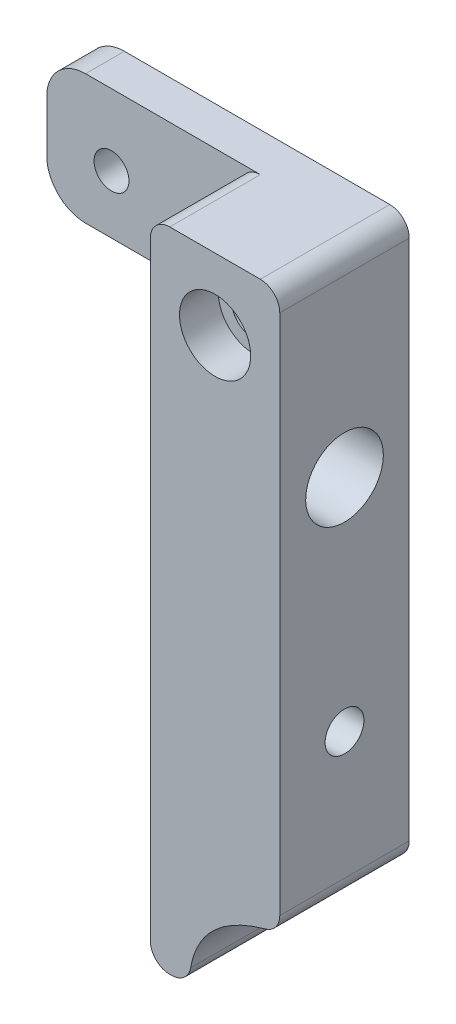
from build123d import *

# Parameters (mm, degrees)
SKETCH1_W           = 10
SKETCH1_H           = 50
BOSS_EXTRUDE1_DEPTH = 10
SKETCH2_R           = 1.75
CUT_EXTRUDE1_DEPTH  = 10
CUT_EXTRUDE2_DEPTH  = 10
FILLET1_R           = 1.5
SKETCH4_R           = 2.75
CUT_EXTRUDE3_DEPTH  = 3
SKETCH5_R           = 3
CUT_EXTRUDE4_DEPTH  = 13
SKETCH6_W           = 3
SKETCH6_H           = 10
BOSS_EXTRUDE2_DEPTH = 15
FILLET2_R           = 3
FILLET3_R           = 1.5
SKETCH7_R           = 1.35
CUT_EXTRUDE5_DEPTH  = 15
SKETCH8_R           = 1.5
CUT_EXTRUDE6_DEPTH  = 15


with BuildPart() as part:
    # Sketch1 → Boss-Extrude1 (new body)
    with BuildSketch(Plane.XY):
        Rectangle(SKETCH1_W, SKETCH1_H)
    extrude(amount=BOSS_EXTRUDE1_DEPTH)

    # Sketch2 → Cut-Extrude1 (cut)
    with BuildSketch(Plane.XY.offset(10)):
        with Locations((0, 19.5)):
            Circle(SKETCH2_R)
    extrude(amount=-CUT_EXTRUDE1_DEPTH, mode=Mode.SUBTRACT)

    # Sketch3 → Cut-Extrude2 (cut)
    with BuildSketch(Plane.XY.offset(10)):
        with BuildLine():
            Line((5, -18), (5, -25))
            Line((5, -25), (-2, -25))
            add(Edge.make_bspline(
                [(-2, -25), (-1.904224842, -19.430935455), (5, -18)],
                knots=[0, 0, 0, 1, 1, 1], degree=2))
        make_face()
    extrude(amount=-CUT_EXTRUDE2_DEPTH, mode=Mode.SUBTRACT)

    # Fillet1
    fillet1_edges = [part.edges().sort_by_distance(p)[0] for p in [
        (5, -18, 5),
        (-2, -25, 5),
        (-5, -25, 5),
        (5, 25, 5),
    ]]
    fillet(fillet1_edges, radius=FILLET1_R)

    # Sketch4 → Cut-Extrude3 (cut)
    with BuildSketch(Plane.XY.offset(10)):
        with Locations((0, 19.5)):
            Circle(SKETCH4_R)
    extrude(amount=-CUT_EXTRUDE3_DEPTH, mode=Mode.SUBTRACT)

    # Sketch5 → Cut-Extrude4 (cut)
    with BuildSketch(Plane(origin=(5, 0, 0), x_dir=(0, 0, -1), z_dir=(1, 0, 0))):
        with Locations((-5, 10)):
            Circle(SKETCH5_R)
    extrude(amount=-CUT_EXTRUDE4_DEPTH, mode=Mode.SUBTRACT)

    # Sketch6 → Boss-Extrude2 (add)
    with BuildSketch(Plane.ZY.offset(5)):
        with Locations((1.5, 20)):
            Rectangle(SKETCH6_W, SKETCH6_H)
    extrude(amount=BOSS_EXTRUDE2_DEPTH)

    # Fillet2
    fillet2_edges = [part.edges().sort_by_distance(p)[0] for p in [
        (-20, 15, 1.5),
        (-20, 25, 1.5),
    ]]
    fillet(fillet2_edges, radius=FILLET2_R)

    # Fillet3
    fillet3_edges = [part.edges().sort_by_distance(p)[0] for p in [
        (-5, 25, 6.5),
    ]]
    fillet(fillet3_edges, radius=FILLET3_R)

    # Sketch7 → Cut-Extrude5 (cut)
    with BuildSketch(Plane.XY.offset(3)):
        with Locations((-15, 19.5)):
            Circle(SKETCH7_R)
    extrude(amount=-CUT_EXTRUDE5_DEPTH, mode=Mode.SUBTRACT)

    # Sketch8 → Cut-Extrude6 (cut)
    with BuildSketch(Plane(origin=(5, 0, 0), x_dir=(0, 0, -1), z_dir=(1, 0, 0))):
        with Locations((-5, -7)):
            Circle(SKETCH8_R)
    extrude(amount=-CUT_EXTRUDE6_DEPTH, mode=Mode.SUBTRACT)


solid = part.part
